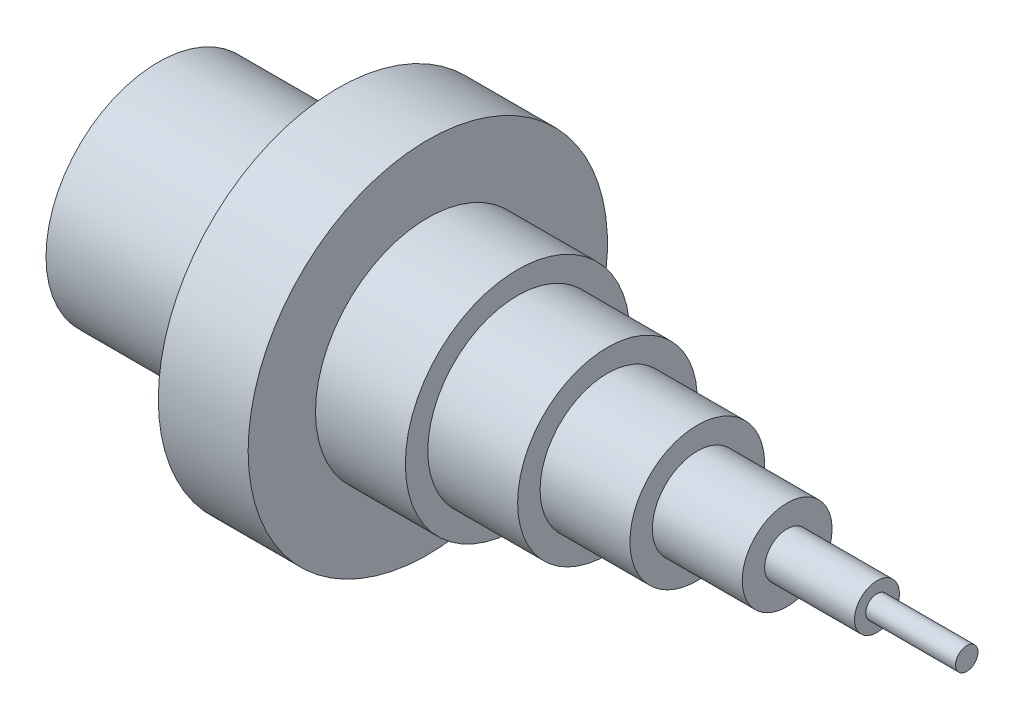
from build123d import *

# Parameters (mm, degrees)
SKETCH2_R          = 20
CUT_EXTRUDE1_DEPTH = 40


with BuildPart() as part:
    # Sketch1 → Revolve1 (revolve)
    with BuildSketch(Plane(origin=(0, 0, 0), x_dir=(1, 0, 0), z_dir=(0, 1, 0)), mode=Mode.PRIVATE) as revolve1_sk:
        Polygon((0, 0), (0, 25), (40, 25), (40, 40), (60, 40), (60, 25), (80, 25), (80, 20), (100, 20), (100, 15), (120, 15), (120, 10), (140, 10), (140, 5), (160, 5), (160, 2.5), (180, 2.5), (180, 0), align=None)
    revolve(revolve1_sk.sketch.rotate(Axis((-28.888888889, 0, 0), (1, 0, 0)), 180), axis=Axis((-28.888888889, 0, 0), (1, 0, 0)))  # turned: the seam where the file's is

    # Sketch2 → Cut-Extrude1 (cut)
    with BuildSketch(Plane.ZY):
        Circle(SKETCH2_R)
    extrude(amount=-CUT_EXTRUDE1_DEPTH, mode=Mode.SUBTRACT)


solid = part.part
